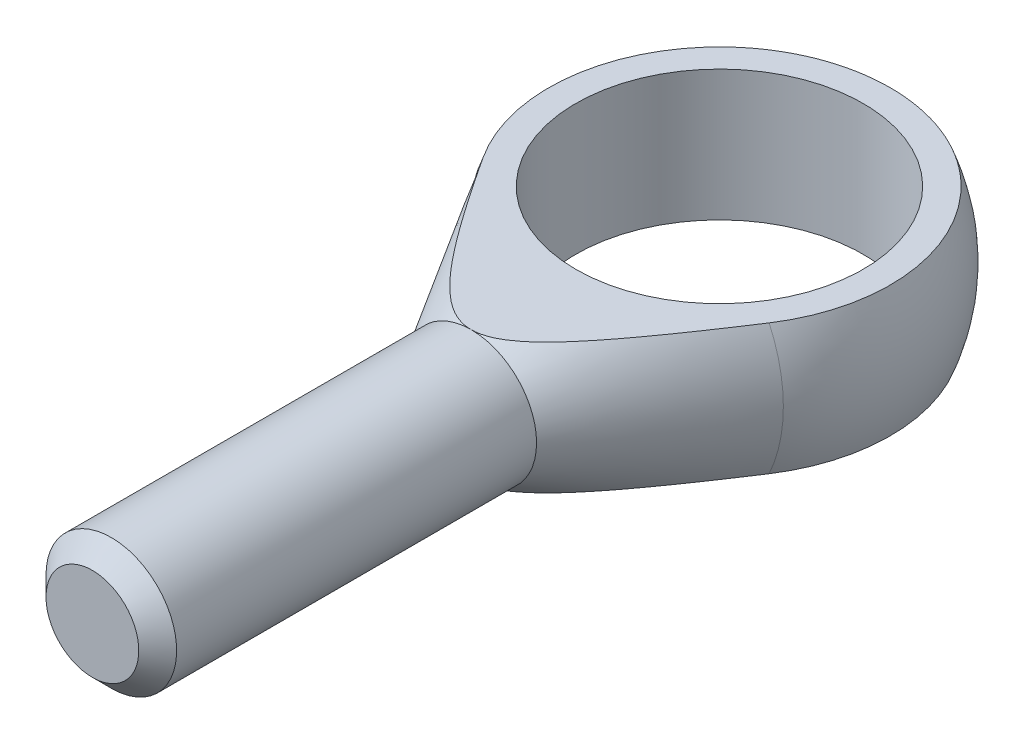
from build123d import *

# Parameters (mm, degrees)
SZKIC1_W                        = 5
SZKIC1_H                        = 29
WYTNIJ_WYCI_GNI_CIE1_DEPTH      = 15
WYTNIJ_WYCI_GNI_CIE1_DEPTH_BACK = 15
SZKIC3_R                        = 11
WYTNIJ_WYCI_GNI_CIE2_DEPTH      = 6
WYTNIJ_WYCI_GNI_CIE2_DEPTH_BACK = 6
SFAZOWANIE1_SIZE                = 1.45


with BuildPart() as part:
    # Szkic1 → Obrót1 (revolve)
    with BuildSketch(Plane(origin=(0, 0, 0), x_dir=(1, 0, 0), z_dir=(0, 1, 0))):
        with BuildLine():
            Line((0, 14), (0, -19))
            Line((0, -19), (5, -19))
            Line((5, -19), (12.037712352, -7.147970434))
            ThreePointArc((12.037712352, -7.147970434), (12.166996056, 6.925619609), (0, 14))
        make_face()
        with Locations((2.5, -33.5)):
            Rectangle(SZKIC1_W, SZKIC1_H)
    revolve(axis=Axis((0, 0, -26.043516498), (0, 0, 1)))

    # Szkic2 → Wytnij-wyciągnięcie1 (cut, two sides)
    with BuildSketch(Plane(origin=(0, 0, 0), x_dir=(0, 0, -1), z_dir=(1, 0, 0))) as wytnij_wyci_gni_cie1_sk:
        with BuildLine():
            Line((-19, 5), (13.076696831, 5))
            ThreePointArc((13.076696831, 5), (4.601064873, 13.222337238), (-7.147970434, 12.037712352))
            Line((-7.147970434, 12.037712352), (-19, 5))
        make_face()
        with BuildLine():
            Line((-19, -5), (13.076696831, -5))
            ThreePointArc((13.076696831, -5), (4.601064873, -13.222337238), (-7.147970434, -12.037712352))
            Line((-7.147970434, -12.037712352), (-19, -5))
        make_face()
    extrude(amount=WYTNIJ_WYCI_GNI_CIE1_DEPTH, mode=Mode.SUBTRACT)
    extrude(wytnij_wyci_gni_cie1_sk.sketch, amount=-WYTNIJ_WYCI_GNI_CIE1_DEPTH_BACK, mode=Mode.SUBTRACT)

    # Szkic3 → Wytnij-wyciągnięcie2 (cut, two sides)
    with BuildSketch(Plane(origin=(0, 0, 0), x_dir=(1, 0, 0), z_dir=(0, 1, 0))) as wytnij_wyci_gni_cie2_sk:
        Circle(SZKIC3_R)
    extrude(amount=WYTNIJ_WYCI_GNI_CIE2_DEPTH, mode=Mode.SUBTRACT)
    extrude(wytnij_wyci_gni_cie2_sk.sketch, amount=-WYTNIJ_WYCI_GNI_CIE2_DEPTH_BACK, mode=Mode.SUBTRACT)

    # Sfazowanie1
    sfazowanie1_edges = [part.edges().sort_by_distance(p)[0] for p in [
        (-5, 0, 48),
    ]]
    chamfer(sfazowanie1_edges, length=SFAZOWANIE1_SIZE)


solid = part.part
